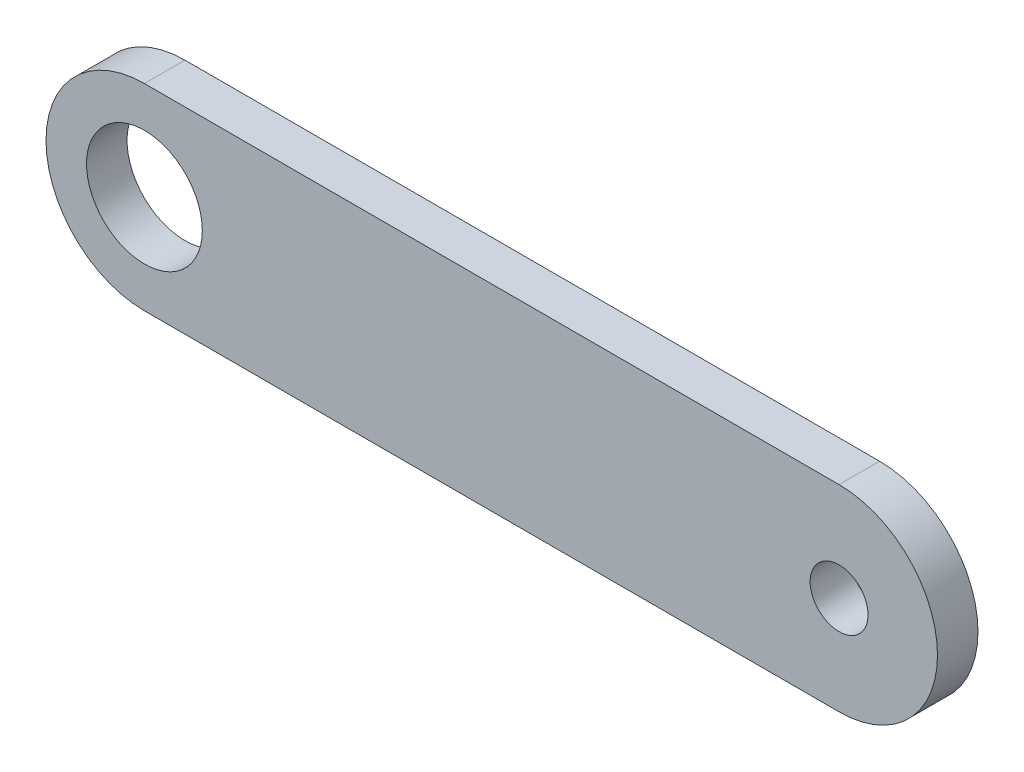
from build123d import *

# Parameters (mm, degrees)
SKETCH_1_R      = 2.5
SKETCH_1_R_2    = 5
EXTRUDE_1_DEPTH = 3.5


with BuildPart() as part:
    # 草图1 → 凸台-拉伸1 (new body)
    with BuildSketch(Plane.XY):
        with BuildLine():
            Line((30, 8.5), (-30, 8.5))
            ThreePointArc((-30, 8.5), (-38.5, 0), (-30, -8.5))
            Line((-30, -8.5), (30, -8.5))
            ThreePointArc((30, -8.5), (38.5, 0), (30, 8.5))
        make_face()
        with Locations((30, 0)):
            Circle(SKETCH_1_R, mode=Mode.SUBTRACT)
        with Locations((-30, 0)):
            Circle(SKETCH_1_R_2, mode=Mode.SUBTRACT)
    extrude(amount=EXTRUDE_1_DEPTH)


solid = part.part
